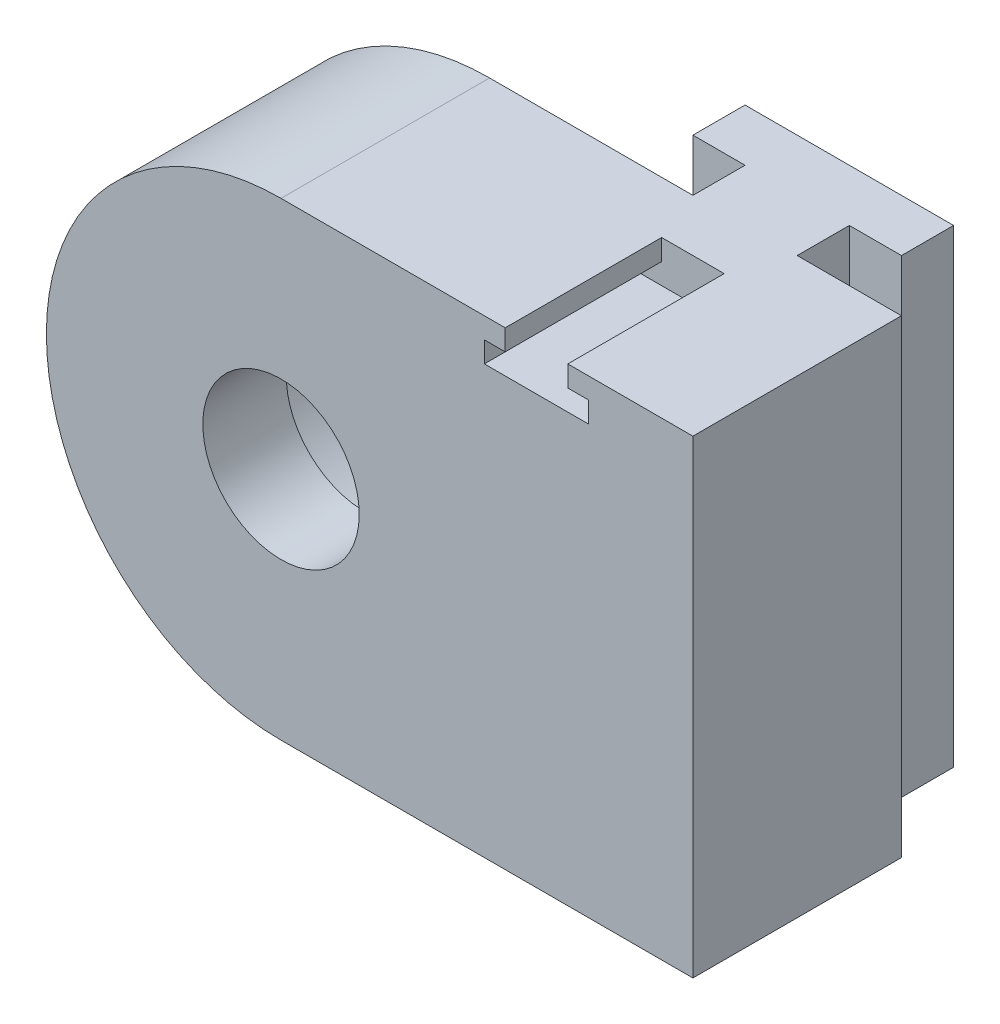
from build123d import *

# Parameters (mm, degrees)
ESQUISSE1_R                  = 7.5
BOSS_EXTRU_1_DEPTH           = 10
ENL_V_MAT_EXTRU_1_DEPTH      = 2
ENL_V_MAT_EXTRU_1_DEPTH_BACK = 10
ESQUISSE1_5_R                = 14
BOSS_EXTRU_2_DEPTH           = 45
ENL_V_MAT_EXTRU_2_DEPTH      = 658.768842069
ENL_V_MAT_EXTRU_2_DEPTH_BACK = 5


with BuildPart() as part:
    # Esquisse1 → Boss.-Extru.1 (new, symmetric)
    with BuildSketch(Plane.XY):
        with BuildLine():
            Line((-634.508066615, 20.5), (-595.008671928, 20.5))
            Line((-595.008671928, 20.5), (-595.008671928, -24.5))
            Line((-595.008671928, -24.5), (-634.508066615, -24.5))
            ThreePointArc((-634.508066615, -24.5), (-657.008066615, -2), (-634.508066615, 20.5))
        make_face()
        with Locations((-634.508066615, -2)):
            Circle(ESQUISSE1_R, mode=Mode.SUBTRACT)
    extrude(amount=BOSS_EXTRU_1_DEPTH, both=True)

    # Esquisse1_5 → Enl_v. mat.-Extru.1 (cut, two sides: drawn at the far end of the back side and taken through both)
    with BuildSketch(Plane.XY.offset(-ENL_V_MAT_EXTRU_1_DEPTH_BACK)):
        with Locations((-634.508066615, -2)):
            Circle(ESQUISSE1_5_R)
    extrude(amount=ENL_V_MAT_EXTRU_1_DEPTH + ENL_V_MAT_EXTRU_1_DEPTH_BACK, mode=Mode.SUBTRACT)

    # Esquisse2 → Boss.-Extru.2 (add)
    with BuildSketch(Plane(origin=(0, 20.5, 0), x_dir=(1, 0, 0), z_dir=(0, 1, 0))):
        Polygon((-605.008671928, 10), (-605.008671928, 15), (-600.008671928, 15), (-600.008671928, 20), (-620.008671928, 20), (-620.008671928, 15), (-615.008671928, 15), (-615.008671928, 10), align=None)
    extrude(amount=-BOSS_EXTRU_2_DEPTH)

    # Esquisse1_7 → Enl_v. mat.-Extru.2 (cut, two sides: drawn at the far end of the back side and taken through both)
    with BuildSketch(Plane.XY.offset(-ENL_V_MAT_EXTRU_2_DEPTH_BACK)):
        Polygon((-607.008671928, 20.5), (-613.008671928, 20.5), (-613.008671928, 18.5), (-615.008671928, 18.5), (-615.008671928, 16.5), (-605.008671928, 16.5), (-605.008671928, 18.5), (-607.008671928, 18.5), align=None)
    extrude(amount=ENL_V_MAT_EXTRU_2_DEPTH + ENL_V_MAT_EXTRU_2_DEPTH_BACK, mode=Mode.SUBTRACT)


solid = part.part
